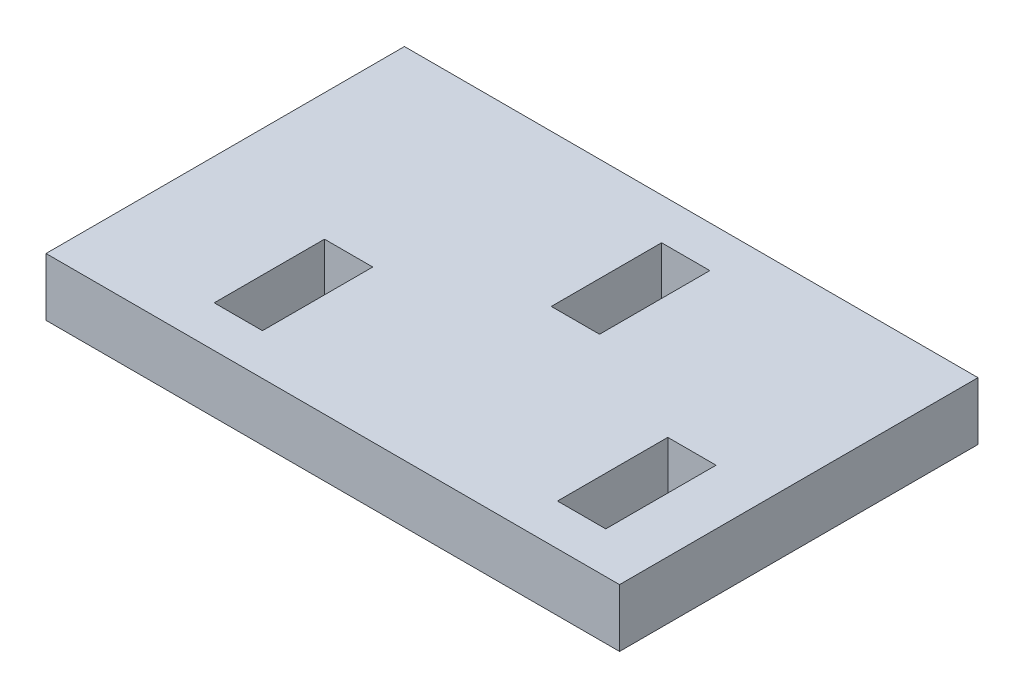
from build123d import *

# Parameters (mm, degrees)
SKETCH1_W           = 52.832
SKETCH1_H           = 33.02
BOSS_EXTRUDE1_DEPTH = 5.334
SKETCH2_W           = 4.445
SKETCH2_H           = 10.16
CUT_EXTRUDE1_DEPTH  = 6.334


with BuildPart() as part:
    # Sketch1 → Boss-Extrude1 (new body)
    with BuildSketch(Plane(origin=(0, 0, 0), x_dir=(1, 0, 0), z_dir=(0, 1, 0))):
        Rectangle(SKETCH1_W, SKETCH1_H)
    extrude(amount=BOSS_EXTRUDE1_DEPTH)

    # Sketch2 → Cut-Extrude1 (cut, through all)
    with BuildSketch(Plane(origin=(0, 5.334, 0), x_dir=(1, 0, 0), z_dir=(0, 1, 0))):
        with Locations((19.1135, -7.62)):
            Rectangle(SKETCH2_W, SKETCH2_H)
        with Locations((3.302, 7.62)):
            Rectangle(SKETCH2_W, SKETCH2_H)
        with Locations((-12.5095, -7.62)):
            Rectangle(SKETCH2_W, SKETCH2_H)
    extrude(amount=-CUT_EXTRUDE1_DEPTH, mode=Mode.SUBTRACT)


solid = part.part
